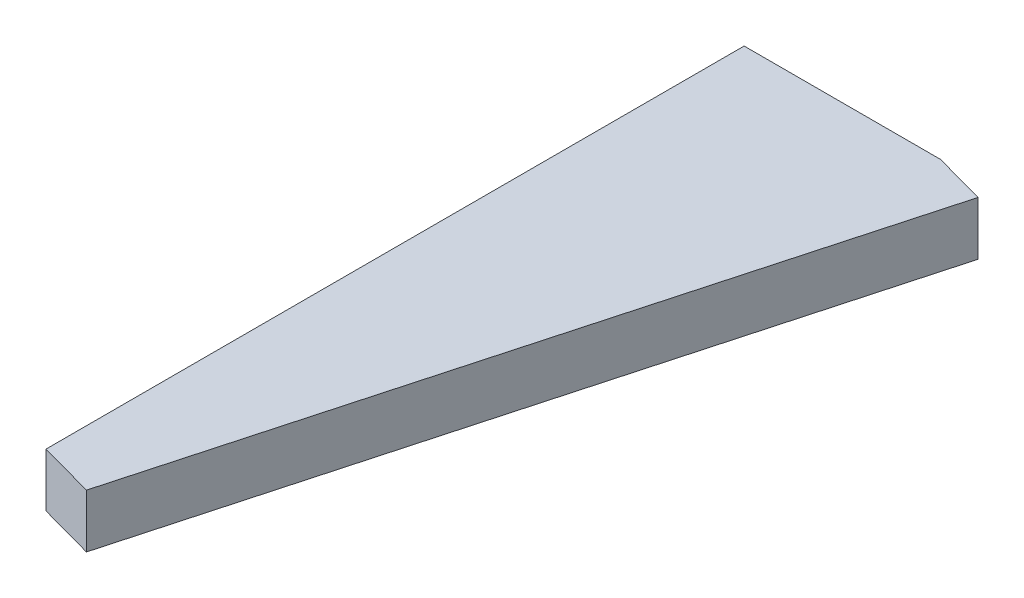
from build123d import *

# Parameters (mm, degrees)
BOSS_EXTRUDE2_DEPTH = 3


with BuildPart() as part:
    # Sketch1 → Boss-Extrude2 (new body)
    with BuildSketch(Plane(origin=(0, 0, 0), x_dir=(1, 0, 0), z_dir=(0, 1, 0))):
        Polygon((13.892616178, 39.204530551), (11, 40), (0, 40), (0, 0.90229738), (3.123302319, 0.043389243), align=None)
    extrude(amount=BOSS_EXTRUDE2_DEPTH)


solid = part.part
